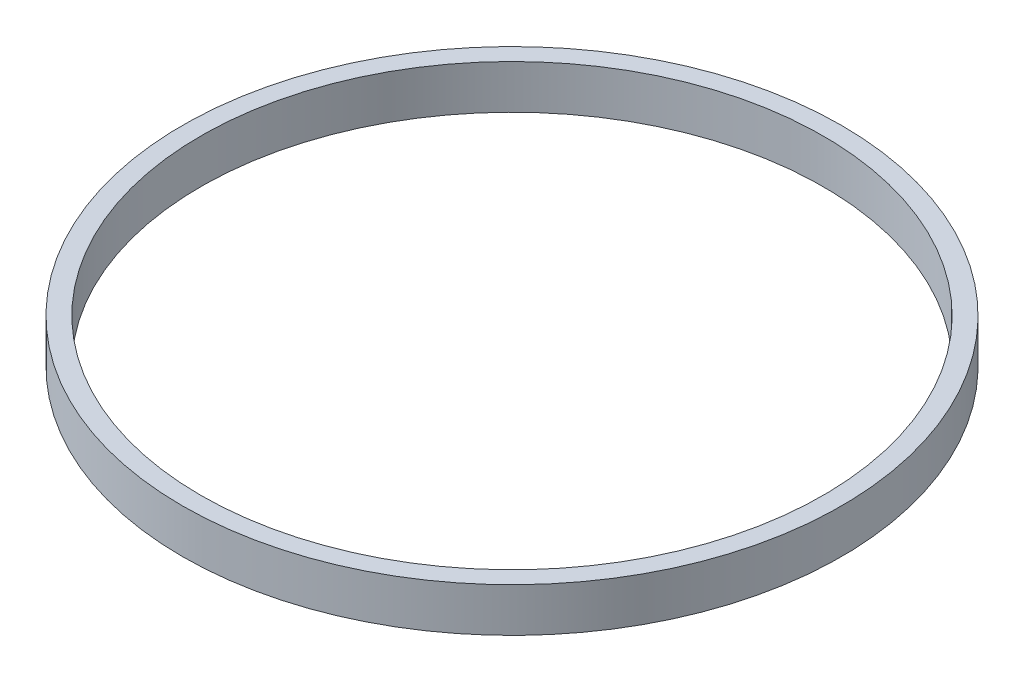
from build123d import *

# Parameters (mm, degrees)
SKETCH_1_R      = 45
SKETCH_1_R_2    = 42.5
EXTRUDE_1_DEPTH = 6


with BuildPart() as part:
    # 草图1 → 凸台-拉伸1 (new body)
    with BuildSketch(Plane(origin=(0, 0, 0), x_dir=(1, 0, 0), z_dir=(0, 1, 0))):
        Circle(SKETCH_1_R)
        Circle(SKETCH_1_R_2, mode=Mode.SUBTRACT)
    extrude(amount=EXTRUDE_1_DEPTH)


solid = part.part
